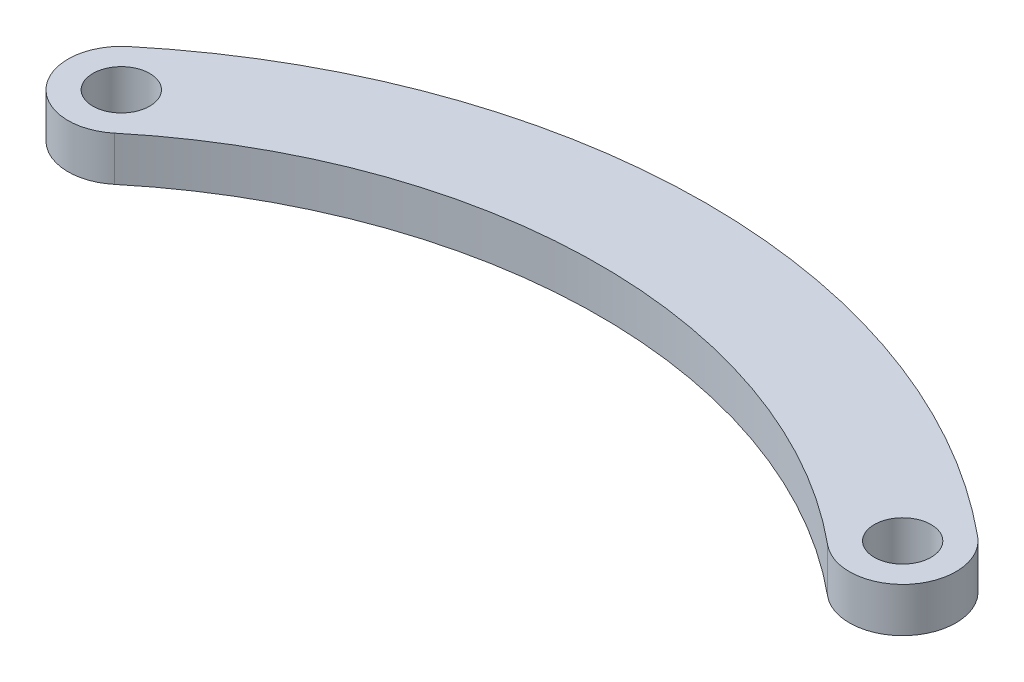
from build123d import *

# Parameters (mm, degrees)
SKETCH_1_R      = 1.6
EXTRUDE_1_DEPTH = 2.5


with BuildPart() as part:
    # 草图1 → 凸台-拉伸1 (new body)
    with BuildSketch(Plane(origin=(0, 0, 0), x_dir=(1, 0, 0), z_dir=(0, 1, 0))):
        with BuildLine():
            ThreePointArc((45.915499445, 2.308865928), (22, 10.937851204), (-1.915499445, 2.308865928))
            ThreePointArc((-1.915499445, 2.308865928), (-2.308865928, -1.915499445), (1.915499445, -2.308865928))
            ThreePointArc((1.915499445, -2.308865928), (22, 4.937851204), (42.084500555, -2.308865928))
            ThreePointArc((42.084500555, -2.308865928), (46.308865928, -1.915499445), (45.915499445, 2.308865928))
        make_face()
        Circle(SKETCH_1_R, mode=Mode.SUBTRACT)
        with Locations((44, 0)):
            Circle(SKETCH_1_R, mode=Mode.SUBTRACT)
    extrude(amount=EXTRUDE_1_DEPTH)


solid = part.part
